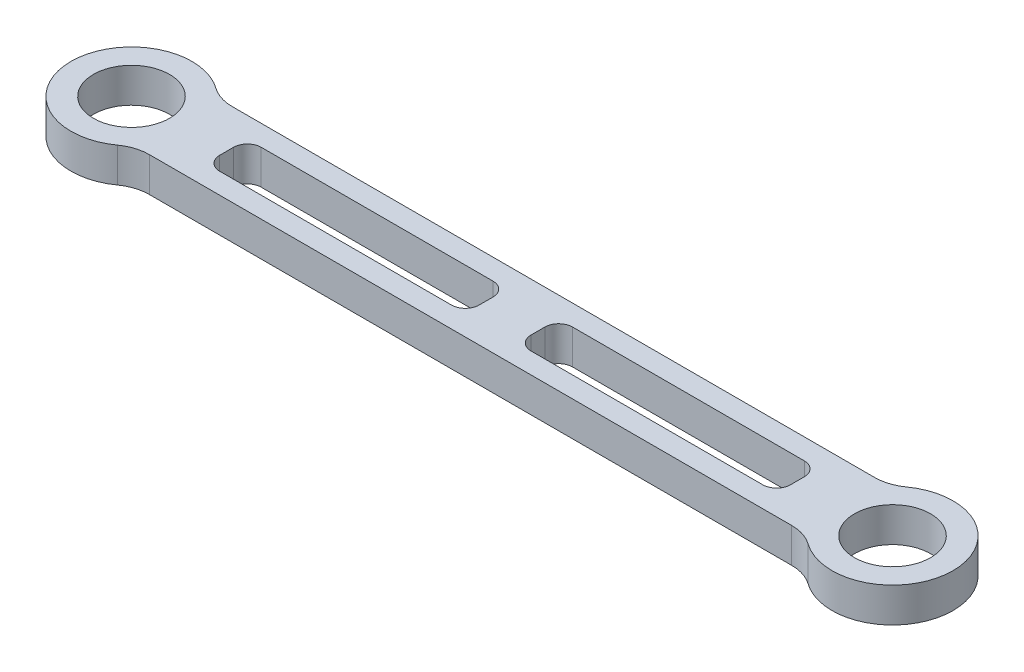
from build123d import *

# Parameters (mm, degrees)
SKETCH1_W           = 75
SKETCH1_H           = 12
SKETCH1_R           = 17.5
SKETCH1_R_2         = 11
BOSS_EXTRUDE1_DEPTH = 10
FILLET1_R           = 4
FILLET2_R           = 12


with BuildPart() as part:
    # Sketch1 → Boss-Extrude1 (new body)
    with BuildSketch(Plane(origin=(0, 0, 0), x_dir=(1, 0, 0), z_dir=(0, 1, 0))):
        with BuildLine():
            Line((197.072466256, 12), (12.737739203, 12))
            ThreePointArc((12.737739203, 12), (16.265921985, 6.45521355), (17.5, 0))
            ThreePointArc((17.5, 0), (16.265921985, -6.45521355), (12.737739203, -12))
            Line((12.737739203, -12), (207.262260797, -12))
            ThreePointArc((207.262260797, -12), (202.5, 0), (207.262260797, 12))
            Line((207.262260797, 12), (197.072466256, 12))
        make_face()
        with Locations((65, 0)):
            Rectangle(SKETCH1_W, SKETCH1_H, mode=Mode.SUBTRACT)
        with Locations((155, 0)):
            Rectangle(SKETCH1_W, SKETCH1_H, mode=Mode.SUBTRACT)
        Circle(SKETCH1_R)
        Circle(SKETCH1_R_2, mode=Mode.SUBTRACT)
        with Locations((220, 0)):
            Circle(SKETCH1_R)
        with Locations((220, 0)):
            Circle(SKETCH1_R_2, mode=Mode.SUBTRACT)
    extrude(amount=BOSS_EXTRUDE1_DEPTH)

    # Fillet1
    fillet1_edges = [part.edges().sort_by_distance(p)[0] for p in [
        (27.5, 5, -6),
        (27.5, 5, 6),
        (102.5, 5, 6),
        (102.5, 5, -6),
        (117.5, 5, -6),
        (117.5, 5, 6),
        (192.5, 5, 6),
        (192.5, 5, -6),
    ]]
    fillet(fillet1_edges, radius=FILLET1_R)

    # Fillet2
    fillet2_edges = [part.edges().sort_by_distance(p)[0] for p in [
        (12.737739203, 5, 12),
        (12.737739203, 5, -12),
        (207.262260797, 5, -12),
        (207.262260797, 5, 12),
    ]]
    fillet(fillet2_edges, radius=FILLET2_R)


solid = part.part
